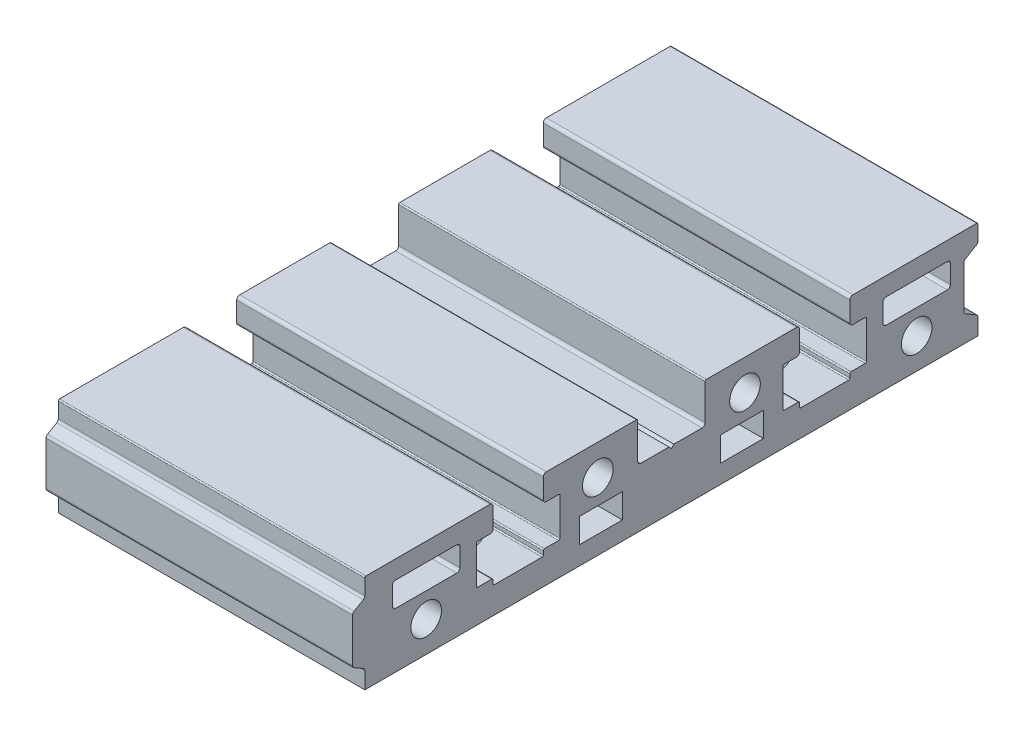
from build123d import *

# Parameters (mm, degrees)
SKETCH_1_R            = 2.5
SKETCH_1_W            = 7
SKETCH_1_H            = 4
EXTRUDE_1_DEPTH       = 50
HOLE_WIZARD_6_0_6_1_D = 6


with BuildPart() as part:
    # Эскиз1 → Бобышка-Вытянуть1 (new body)
    with BuildSketch(Plane(origin=(0, 0, 0), x_dir=(0, 0, -1), z_dir=(1, 0, 0))):
        with BuildLine():
            Line((-5.5, 15.8), (-5.5, 10))
            ThreePointArc((-5.5, 10), (-5.353553391, 9.646446609), (-5, 9.5))
            Line((-5, 9.5), (-0.4, 9.5))
            Line((-0.4, 9.5), (0, 9.1))
            Line((0, 9.1), (0.4, 9.5))
            Line((0.4, 9.5), (5, 9.5))
            ThreePointArc((5, 9.5), (5.353553391, 9.646446609), (5.5, 10))
            Line((5.5, 10), (5.5, 15.8))
            ThreePointArc((5.5, 15.8), (5.558578644, 15.941421356), (5.7, 16))
            Line((5.7, 16), (20.4, 16))
            ThreePointArc((20.4, 16), (20.753553391, 15.853553391), (20.9, 15.5))
            Line((20.9, 15.5), (20.9, 12.3))
            ThreePointArc((20.9, 12.3), (20.753553391, 11.946446609), (20.4, 11.8))
            Line((20.4, 11.8), (18.4, 11.8))
            ThreePointArc((18.4, 11.8), (18.258578644, 11.741421356), (18.2, 11.6))
            Line((18.2, 11.6), (18.2, 5.5))
            ThreePointArc((18.2, 5.5), (18.258578644, 5.358578644), (18.4, 5.3))
            Line((18.4, 5.3), (20.7, 5.3))
            ThreePointArc((20.7, 5.3), (20.841421356, 5.241421356), (20.9, 5.1))
            Line((20.9, 5.1), (20.9, 4.5))
            ThreePointArc((20.9, 4.5), (20.958578644, 4.358578644), (21.1, 4.3))
            Line((21.1, 4.3), (28.9, 4.3))
            ThreePointArc((28.9, 4.3), (29.041421356, 4.358578644), (29.1, 4.5))
            Line((29.1, 4.5), (29.1, 5.1))
            ThreePointArc((29.1, 5.1), (29.158578644, 5.241421356), (29.3, 5.3))
            Line((29.3, 5.3), (31.6, 5.3))
            ThreePointArc((31.6, 5.3), (31.741421356, 5.358578644), (31.8, 5.5))
            Line((31.8, 5.5), (31.8, 11.6))
            ThreePointArc((31.8, 11.6), (31.741421356, 11.741421356), (31.6, 11.8))
            Line((31.6, 11.8), (29.6, 11.8))
            ThreePointArc((29.6, 11.8), (29.246446609, 11.946446609), (29.1, 12.3))
            Line((29.1, 12.3), (29.1, 15.5))
            ThreePointArc((29.1, 15.5), (29.246446609, 15.853553391), (29.6, 16))
            Line((29.6, 16), (49.8, 16))
            ThreePointArc((49.8, 16), (49.941421356, 15.941421356), (50, 15.8))
            Line((50, 15.8), (50, 13.378675135))
            ThreePointArc((50, 13.378675135), (49.933012702, 13.128675135), (49.75, 12.945662433))
            Line((49.75, 12.945662433), (47.95, 11.906431948))
            ThreePointArc((47.95, 11.906431948), (47.766987298, 11.723419246), (47.7, 11.473419246))
            Line((47.7, 11.473419246), (47.7, 4.566580754))
            ThreePointArc((47.7, 4.566580754), (47.766987298, 4.316580754), (47.95, 4.133568052))
            Line((47.95, 4.133568052), (49.75, 3.094337567))
            ThreePointArc((49.75, 3.094337567), (49.933012702, 2.911324865), (50, 2.661324865))
            Line((50, 2.661324865), (50, 0))
            Line((50, 0), (-50, 0))
            Line((-50, 0), (-50, 2.711324865))
            ThreePointArc((-50, 2.711324865), (-50.066987298, 2.961324865), (-50.25, 3.144337567))
            Line((-50.25, 3.144337567), (-51.75, 4.010362971))
            ThreePointArc((-51.75, 4.010362971), (-51.933012702, 4.193375673), (-52, 4.443375673))
            Line((-52, 4.443375673), (-52, 11.556624327))
            ThreePointArc((-52, 11.556624327), (-51.933012702, 11.806624327), (-51.75, 11.989637029))
            Line((-51.75, 11.989637029), (-50.25, 12.855662433))
            ThreePointArc((-50.25, 12.855662433), (-50.066987298, 13.038675135), (-50, 13.288675135))
            Line((-50, 13.288675135), (-50, 15.8))
            ThreePointArc((-50, 15.8), (-49.941421356, 15.941421356), (-49.8, 16))
            Line((-49.8, 16), (-29.6, 16))
            ThreePointArc((-29.6, 16), (-29.246446609, 15.853553391), (-29.1, 15.5))
            Line((-29.1, 15.5), (-29.1, 12.3))
            ThreePointArc((-29.1, 12.3), (-29.246446609, 11.946446609), (-29.6, 11.8))
            Line((-29.6, 11.8), (-31.6, 11.8))
            ThreePointArc((-31.6, 11.8), (-31.741421356, 11.741421356), (-31.8, 11.6))
            Line((-31.8, 11.6), (-31.8, 5.5))
            ThreePointArc((-31.8, 5.5), (-31.741421356, 5.358578644), (-31.6, 5.3))
            Line((-31.6, 5.3), (-29.3, 5.3))
            ThreePointArc((-29.3, 5.3), (-29.158578644, 5.241421356), (-29.1, 5.1))
            Line((-29.1, 5.1), (-29.1, 4.5))
            ThreePointArc((-29.1, 4.5), (-29.041421356, 4.358578644), (-28.9, 4.3))
            Line((-28.9, 4.3), (-21.1, 4.3))
            ThreePointArc((-21.1, 4.3), (-20.958578644, 4.358578644), (-20.9, 4.5))
            Line((-20.9, 4.5), (-20.9, 5.1))
            ThreePointArc((-20.9, 5.1), (-20.841421356, 5.241421356), (-20.7, 5.3))
            Line((-20.7, 5.3), (-18.4, 5.3))
            ThreePointArc((-18.4, 5.3), (-18.258578644, 5.358578644), (-18.2, 5.5))
            Line((-18.2, 5.5), (-18.2, 11.6))
            ThreePointArc((-18.2, 11.6), (-18.258578644, 11.741421356), (-18.4, 11.8))
            Line((-18.4, 11.8), (-20.4, 11.8))
            ThreePointArc((-20.4, 11.8), (-20.753553391, 11.946446609), (-20.9, 12.3))
            Line((-20.9, 12.3), (-20.9, 15.5))
            ThreePointArc((-20.9, 15.5), (-20.753553391, 15.853553391), (-20.4, 16))
            Line((-20.4, 16), (-5.7, 16))
            ThreePointArc((-5.7, 16), (-5.558578644, 15.941421356), (-5.5, 15.8))
        make_face()
        with Locations((-12, 11)):
            Circle(SKETCH_1_R, mode=Mode.SUBTRACT)
        with Locations((12, 11)):
            Circle(SKETCH_1_R, mode=Mode.SUBTRACT)
        with Locations((-40, 5)):
            Circle(SKETCH_1_R, mode=Mode.SUBTRACT)
        with Locations((40, 5)):
            Circle(SKETCH_1_R, mode=Mode.SUBTRACT)
        with Locations((-11.5, 5)):
            Rectangle(SKETCH_1_W, SKETCH_1_H, mode=Mode.SUBTRACT)
        with Locations((11.5, 5)):
            Rectangle(SKETCH_1_W, SKETCH_1_H, mode=Mode.SUBTRACT)
        with BuildLine():
            Line((-45, 13), (-35, 13))
            ThreePointArc((-35, 13), (-34.646446609, 12.853553391), (-34.5, 12.5))
            Line((-34.5, 12.5), (-34.5, 9.5))
            ThreePointArc((-34.5, 9.5), (-34.646446609, 9.146446609), (-35, 9))
            Line((-35, 9), (-45, 9))
            ThreePointArc((-45, 9), (-45.353553391, 9.146446609), (-45.5, 9.5))
            Line((-45.5, 9.5), (-45.5, 12.5))
            ThreePointArc((-45.5, 12.5), (-45.353553391, 12.853553391), (-45, 13))
        make_face(mode=Mode.SUBTRACT)
        with BuildLine():
            Line((34.5, 12.5), (34.5, 9.5))
            ThreePointArc((34.5, 9.5), (34.646446609, 9.146446609), (35, 9))
            Line((35, 9), (45, 9))
            ThreePointArc((45, 9), (45.353553391, 9.146446609), (45.5, 9.5))
            Line((45.5, 9.5), (45.5, 12.5))
            ThreePointArc((45.5, 12.5), (45.353553391, 12.853553391), (45, 13))
            Line((45, 13), (35, 13))
            ThreePointArc((35, 13), (34.646446609, 12.853553391), (34.5, 12.5))
        make_face(mode=Mode.SUBTRACT)
    extrude(amount=EXTRUDE_1_DEPTH)

    # Диаметр отверстия Ø6.0 (6)1 (through all)
    with Locations(Plane(origin=(0, 4.3, 0), x_dir=(1, 0, 0), z_dir=(0, 1, 0))):
        with Locations((10, 25), (10, -25), (40, -25), (40, 25)):
            Hole(HOLE_WIZARD_6_0_6_1_D / 2)


solid = part.part
